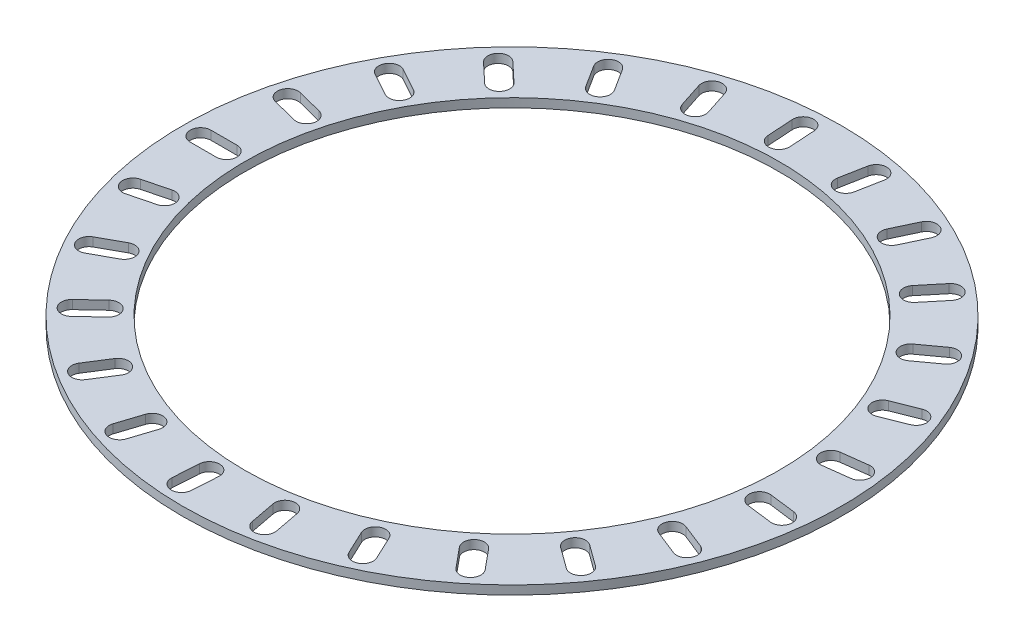
from build123d import *

# Parameters (mm, degrees)
SKETCH1_R           = 31.77
SKETCH1_R_2         = 25.77
BOSS_EXTRUDE1_DEPTH = 0.85
CUT_EXTRUDE1_DEPTH  = 1.85
CIRPATTERN1_COUNT   = 25


with BuildPart() as part:
    # Sketch1 → Boss-Extrude1 (new body)
    with BuildSketch(Plane(origin=(0, 0, 0), x_dir=(1, 0, 0), z_dir=(0, 1, 0))):
        Circle(SKETCH1_R)
        Circle(SKETCH1_R_2, mode=Mode.SUBTRACT)
    extrude(amount=BOSS_EXTRUDE1_DEPTH)

    # Sketch3 → Cut-Extrude1 (cut, through all)
    with BuildSketch(Plane(origin=(0, 0.85, 0), x_dir=(1, 0, 0), z_dir=(0, 1, 0))):
        with BuildLine():
            Line((-30.02, 1), (-27.52, 1))
            ThreePointArc((-27.52, 1), (-26.52, 0), (-27.52, -1))
            Line((-27.52, -1), (-30.02, -1))
            ThreePointArc((-30.02, -1), (-31.02, 0), (-30.02, 1))
        make_face()
    cut_extrude1 = extrude(amount=-CUT_EXTRUDE1_DEPTH, mode=Mode.SUBTRACT)

    # CirPattern1: Cut-Extrude1 ×25 about axis
    cirpattern1_axis = Axis((0, 0, 0), (0, 1, 0))
    for i in range(1, CIRPATTERN1_COUNT):
        add(cut_extrude1.rotate(cirpattern1_axis, i * 360 / CIRPATTERN1_COUNT), mode=Mode.SUBTRACT)


solid = part.part
